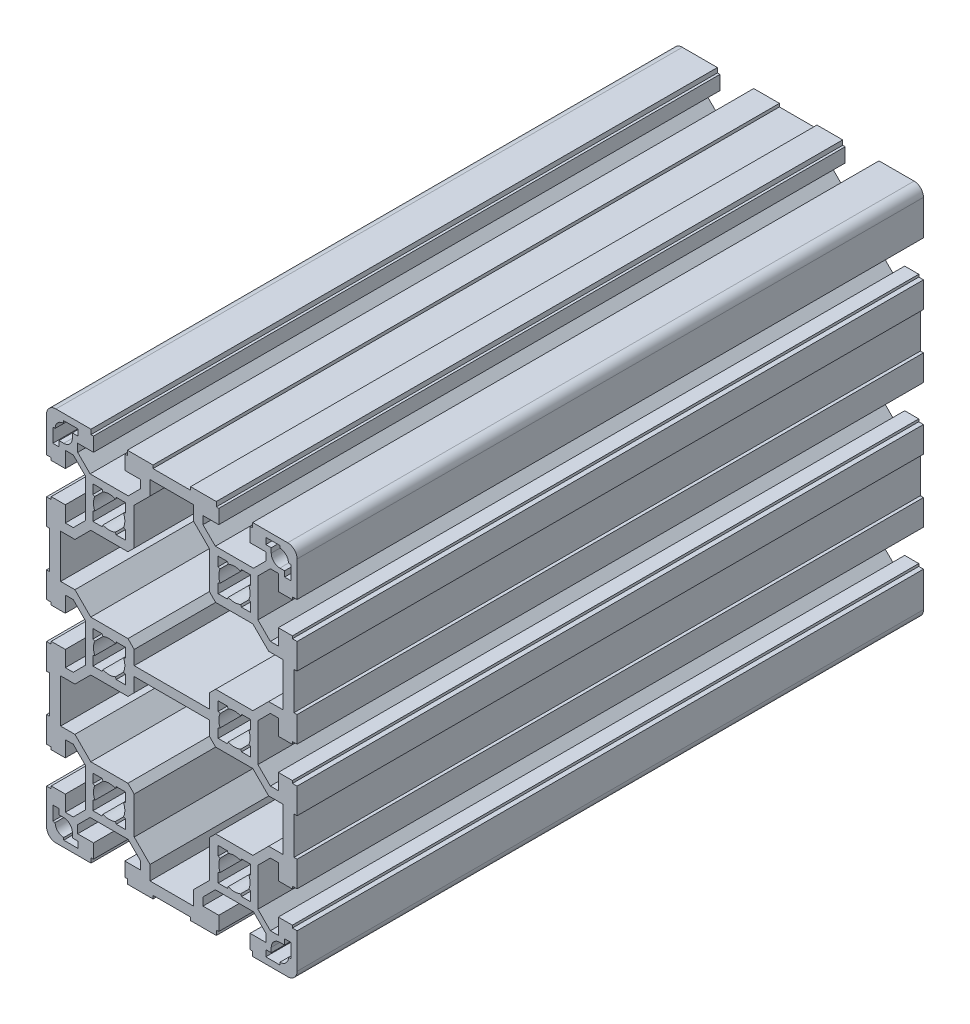
from build123d import *

# Parameters (mm, degrees)
BASE_EXTRUDE_DEPTH = 200


with BuildPart() as part:
    # Sketch1 → Base-Extrude (new body)
    with BuildSketch(Plane.XY):
        with BuildLine():
            Line((27.5, 46.085786046), (31.464214, 50.050000046))
            Line((31.464214, 50.050000046), (34, 50.050000046))
            Line((34, 50.050000046), (34, 45.000000046))
            Line((34, 45.000000046), (38.5, 45.000000046))
            Line((38.5, 45.000000046), (38.5, 45.800000046))
            Line((38.5, 45.800000046), (40, 45.800000046))
            Line((40, 45.800000046), (40, 57.000000046))
            ThreePointArc((40, 57.000000046), (39.121320344, 59.12132039), (37, 60.000000046))
            Line((37, 60.000000046), (25.8, 60.000000046))
            Line((25.8, 60.000000046), (25.8, 58.499999954))
            Line((25.8, 58.499999954), (25, 58.499999954))
            Line((25, 58.499999954), (25, 53.999999954))
            Line((25, 53.999999954), (30.05, 53.999999954))
            Line((30.05, 53.999999954), (30.05, 51.464213954))
            Line((30.05, 51.464213954), (26.085786, 47.499999954))
            Line((26.085786, 47.499999954), (13.914214, 47.499999954))
            Line((13.914214, 47.499999954), (9.95, 51.464213954))
            Line((9.95, 51.464213954), (9.95, 53.999999954))
            Line((9.95, 53.999999954), (15, 53.999999954))
            Line((15, 53.999999954), (15, 58.499999954))
            Line((15, 58.499999954), (14.2, 58.499999954))
            Line((14.2, 58.499999954), (14.2, 59.999999954))
            Line((14.2, 59.999999954), (6, 59.999999954))
            Line((6, 59.999999954), (6, 58.999999954))
            Line((6, 58.999999954), (-6, 58.999999954))
            Line((-6, 58.999999954), (-6, 59.999999954))
            Line((-6, 59.999999954), (-14.2, 59.999999954))
            Line((-14.2, 59.999999954), (-14.2, 58.499999954))
            Line((-14.2, 58.499999954), (-15, 58.499999954))
            Line((-15, 58.499999954), (-15, 53.999999954))
            Line((-15, 53.999999954), (-9.95, 53.999999954))
            Line((-9.95, 53.999999954), (-9.95, 51.464213954))
            Line((-9.95, 51.464213954), (-13.914214, 47.499999954))
            Line((-13.914214, 47.499999954), (-26.085786, 47.499999954))
            Line((-26.085786, 47.499999954), (-30.05, 51.464213954))
            Line((-30.05, 51.464213954), (-30.05, 53.999999954))
            Line((-30.05, 53.999999954), (-25, 53.999999954))
            Line((-25, 53.999999954), (-25, 58.499999954))
            Line((-25, 58.499999954), (-25.8, 58.499999954))
            Line((-25.8, 58.499999954), (-25.8, 60.000000046))
            Line((-25.8, 60.000000046), (-37, 60.000000046))
            ThreePointArc((-37, 60.000000046), (-39.121320344, 59.12132039), (-40, 57.000000046))
            Line((-40, 57.000000046), (-40, 45.800000046))
            Line((-40, 45.800000046), (-38.5, 45.800000046))
            Line((-38.5, 45.800000046), (-38.5, 45.000000046))
            Line((-38.5, 45.000000046), (-34, 45.000000046))
            Line((-34, 45.000000046), (-34, 50.050000046))
            Line((-34, 50.050000046), (-31.464214, 50.050000046))
            Line((-31.464214, 50.050000046), (-27.5, 46.085786046))
            Line((-27.5, 46.085786046), (-27.5, 33.914214047))
            Line((-27.5, 33.914214047), (-31.464214, 29.950000047))
            Line((-31.464214, 29.950000047), (-34, 29.950000047))
            Line((-34, 29.950000047), (-34, 35.000000047))
            Line((-34, 35.000000047), (-38.5, 35.000000047))
            Line((-38.5, 35.000000047), (-38.5, 34.200000047))
            Line((-38.5, 34.200000047), (-40, 34.200000047))
            Line((-40, 34.200000047), (-40, 26.000000047))
            Line((-40, 26.000000047), (-39, 26.000000047))
            Line((-39, 26.000000047), (-39, 14.000000047))
            Line((-39, 14.000000047), (-40, 14.000000047))
            Line((-40, 14.000000047), (-40, 5.800000047))
            Line((-40, 5.800000047), (-38.5, 5.800000047))
            Line((-38.5, 5.800000047), (-38.5, 5.000000047))
            Line((-38.5, 5.000000047), (-34, 5.000000047))
            Line((-34, 5.000000047), (-34, 10.050000047))
            Line((-34, 10.050000047), (-31.464214, 10.050000047))
            Line((-31.464214, 10.050000047), (-27.5, 6.085786047))
            Line((-27.5, 6.085786047), (-27.5, -6.085786045))
            Line((-27.5, -6.085786045), (-31.464214, -10.050000045))
            Line((-31.464214, -10.050000045), (-34, -10.050000045))
            Line((-34, -10.050000045), (-34, -5.000000045))
            Line((-34, -5.000000045), (-38.5, -5.000000045))
            Line((-38.5, -5.000000045), (-38.5, -5.800000045))
            Line((-38.5, -5.800000045), (-40, -5.800000045))
            Line((-40, -5.800000045), (-40, -14.000000045))
            Line((-40, -14.000000045), (-39, -14.000000045))
            Line((-39, -14.000000045), (-39, -26.000000045))
            Line((-39, -26.000000045), (-40, -26.000000045))
            Line((-40, -26.000000045), (-40, -34.200000045))
            Line((-40, -34.200000045), (-38.5, -34.200000045))
            Line((-38.5, -34.200000045), (-38.5, -35.000000045))
            Line((-38.5, -35.000000045), (-34, -35.000000045))
            Line((-34, -35.000000045), (-34, -29.950000045))
            Line((-34, -29.950000045), (-31.464214, -29.950000045))
            Line((-31.464214, -29.950000045), (-27.5, -33.914214045))
            Line((-27.5, -33.914214045), (-27.5, -46.085786044))
            Line((-27.5, -46.085786044), (-31.464214, -50.050000044))
            Line((-31.464214, -50.050000044), (-34, -50.050000044))
            Line((-34, -50.050000044), (-34, -45.000000044))
            Line((-34, -45.000000044), (-38.5, -45.000000044))
            Line((-38.5, -45.000000044), (-38.5, -45.800000044))
            Line((-38.5, -45.800000044), (-40, -45.800000044))
            Line((-40, -45.800000044), (-40, -57.000000044))
            ThreePointArc((-40, -57.000000044), (-39.121320344, -59.121320388), (-37, -60.000000044))
            Line((-37, -60.000000044), (-25.8, -60.000000044))
            Line((-25.8, -60.000000044), (-25.8, -58.499999952))
            Line((-25.8, -58.499999952), (-25, -58.499999952))
            Line((-25, -58.499999952), (-25, -53.999999952))
            Line((-25, -53.999999952), (-30.05, -53.999999952))
            Line((-30.05, -53.999999952), (-30.05, -51.464213952))
            Line((-30.05, -51.464213952), (-26.085786, -47.499999952))
            Line((-26.085786, -47.499999952), (-13.914214, -47.499999952))
            Line((-13.914214, -47.499999952), (-9.95, -51.464213952))
            Line((-9.95, -51.464213952), (-9.95, -53.999999952))
            Line((-9.95, -53.999999952), (-15, -53.999999952))
            Line((-15, -53.999999952), (-15, -58.499999952))
            Line((-15, -58.499999952), (-14.2, -58.499999952))
            Line((-14.2, -58.499999952), (-14.2, -59.999999952))
            Line((-14.2, -59.999999952), (-6, -59.999999952))
            Line((-6, -59.999999952), (-6, -58.999999952))
            Line((-6, -58.999999952), (6, -58.999999952))
            Line((6, -58.999999952), (6, -59.999999952))
            Line((6, -59.999999952), (14.2, -59.999999952))
            Line((14.2, -59.999999952), (14.2, -58.499999952))
            Line((14.2, -58.499999952), (15, -58.499999952))
            Line((15, -58.499999952), (15, -53.999999952))
            Line((15, -53.999999952), (9.95, -53.999999952))
            Line((9.95, -53.999999952), (9.95, -51.464213952))
            Line((9.95, -51.464213952), (13.914214, -47.499999952))
            Line((13.914214, -47.499999952), (26.085786, -47.499999952))
            Line((26.085786, -47.499999952), (30.05, -51.464213952))
            Line((30.05, -51.464213952), (30.05, -53.999999952))
            Line((30.05, -53.999999952), (25, -53.999999952))
            Line((25, -53.999999952), (25, -58.499999952))
            Line((25, -58.499999952), (25.8, -58.499999952))
            Line((25.8, -58.499999952), (25.8, -60.000000044))
            Line((25.8, -60.000000044), (37, -60.000000044))
            ThreePointArc((37, -60.000000044), (39.121320344, -59.121320388), (40, -57.000000044))
            Line((40, -57.000000044), (40, -45.800000044))
            Line((40, -45.800000044), (38.5, -45.800000044))
            Line((38.5, -45.800000044), (38.5, -45.000000044))
            Line((38.5, -45.000000044), (34, -45.000000044))
            Line((34, -45.000000044), (34, -50.050000044))
            Line((34, -50.050000044), (31.464214, -50.050000044))
            Line((31.464214, -50.050000044), (27.5, -46.085786044))
            Line((27.5, -46.085786044), (27.5, -33.914214045))
            Line((27.5, -33.914214045), (31.464214, -29.950000045))
            Line((31.464214, -29.950000045), (34, -29.950000045))
            Line((34, -29.950000045), (34, -35.000000045))
            Line((34, -35.000000045), (38.5, -35.000000045))
            Line((38.5, -35.000000045), (38.5, -34.200000045))
            Line((38.5, -34.200000045), (40, -34.200000045))
            Line((40, -34.200000045), (40, -26.000000045))
            Line((40, -26.000000045), (39, -26.000000045))
            Line((39, -26.000000045), (39, -14.000000045))
            Line((39, -14.000000045), (40, -14.000000045))
            Line((40, -14.000000045), (40, -5.800000045))
            Line((40, -5.800000045), (38.5, -5.800000045))
            Line((38.5, -5.800000045), (38.5, -5.000000045))
            Line((38.5, -5.000000045), (34, -5.000000045))
            Line((34, -5.000000045), (34, -10.050000045))
            Line((34, -10.050000045), (31.464214, -10.050000045))
            Line((31.464214, -10.050000045), (27.5, -6.085786045))
            Line((27.5, -6.085786045), (27.5, 6.085786047))
            Line((27.5, 6.085786047), (31.464214, 10.050000047))
            Line((31.464214, 10.050000047), (34, 10.050000047))
            Line((34, 10.050000047), (34, 5.000000047))
            Line((34, 5.000000047), (38.5, 5.000000047))
            Line((38.5, 5.000000047), (38.5, 5.800000047))
            Line((38.5, 5.800000047), (40, 5.800000047))
            Line((40, 5.800000047), (40, 14.000000047))
            Line((40, 14.000000047), (39, 14.000000047))
            Line((39, 14.000000047), (39, 26.000000047))
            Line((39, 26.000000047), (40, 26.000000047))
            Line((40, 26.000000047), (40, 34.200000047))
            Line((40, 34.200000047), (38.5, 34.200000047))
            Line((38.5, 34.200000047), (38.5, 35.000000047))
            Line((38.5, 35.000000047), (34, 35.000000047))
            Line((34, 35.000000047), (34, 29.950000047))
            Line((34, 29.950000047), (31.464214, 29.950000047))
            Line((31.464214, 29.950000047), (27.5, 33.914214047))
            Line((27.5, 33.914214047), (27.5, 46.085786046))
        make_face()
        Polygon((12, 45.878679956), (6.95, 50.928679956), (6.95, 55.499999956), (-6.95, 55.499999956), (-6.95, 50.928679956), (-12, 45.878679956), (-12, 33.999999956), (-14, 31.999999956), (-25.87868, 31.999999956), (-30.92868, 26.949999956), (-35.5, 26.949999956), (-35.5, 13.049999954), (-30.92868, 13.049999954), (-25.87868, 7.999999954), (-14, 7.999999954), (-12, 5.999999954), (-12, 1.499999954), (12, 1.499999954), (12, 5.999999954), (14, 7.999999954), (25.87868, 7.999999954), (30.92868, 13.049999954), (35.5, 13.049999954), (35.5, 26.949999956), (30.92868, 26.949999956), (25.87868, 31.999999956), (14, 31.999999956), (12, 33.999999956), align=None, mode=Mode.SUBTRACT)
        with BuildLine():
            Line((-14.799999974, 2.260288021), (-15.414462038, 1.993198916))
            ThreePointArc((-15.414462038, 1.993198916), (-14.99999997, 1e-09), (-15.414462038, -1.993198914))
            Line((-15.414462038, -1.993198914), (-14.799999974, -2.260288019))
            Line((-14.799999974, -2.260288019), (-14.799999974, -5.199999953))
            Line((-14.799999974, -5.199999953), (-17.73971204, -5.199999953))
            Line((-17.73971204, -5.199999953), (-18.00680104, -4.585537953))
            ThreePointArc((-18.00680104, -4.585537953), (-19.999999985, -5.000000049), (-21.993198935, -4.585537981))
            Line((-21.993198935, -4.585537981), (-22.26028804, -5.200000045))
            Line((-22.26028804, -5.200000045), (-25.199999974, -5.200000045))
            Line((-25.199999974, -5.200000045), (-25.199999974, -2.260287979))
            Line((-25.199999974, -2.260287979), (-24.585537974, -1.993198979))
            ThreePointArc((-24.585537974, -1.993198979), (-25.00000007, 1e-09), (-24.585537974, 1.993198981))
            Line((-24.585537974, 1.993198981), (-25.199999974, 2.260287981))
            Line((-25.199999974, 2.260287981), (-25.199999974, 5.200000047))
            Line((-25.199999974, 5.200000047), (-22.26028804, 5.200000047))
            Line((-22.26028804, 5.200000047), (-21.993198935, 4.585537983))
            ThreePointArc((-21.993198935, 4.585537983), (-19.999999985, 5.000000051), (-18.00680104, 4.585537955))
            Line((-18.00680104, 4.585537955), (-17.73971204, 5.199999955))
            Line((-17.73971204, 5.199999955), (-14.799999974, 5.199999955))
            Line((-14.799999974, 5.199999955), (-14.799999974, 2.260288021))
        make_face(mode=Mode.SUBTRACT)
        with BuildLine():
            Line((34.5, 51.749999954), (36, 51.749999954))
            Line((36, 51.749999954), (36, 49.999999954))
            Line((36, 49.999999954), (38, 49.999999954))
            Line((38, 49.999999954), (38, 54.499999954))
            Line((38, 54.499999954), (37.25, 54.499999954))
            ThreePointArc((37.25, 54.499999954), (36.444543648, 56.444543602), (34.5, 57.249999954))
            Line((34.5, 57.249999954), (34.5, 57.999999954))
            Line((34.5, 57.999999954), (30, 57.999999954))
            Line((30, 57.999999954), (30, 55.999999954))
            Line((30, 55.999999954), (31.75, 55.999999954))
            Line((31.75, 55.999999954), (31.75, 54.499999954))
            ThreePointArc((31.75, 54.499999954), (32.555456352, 52.555456306), (34.5, 51.749999954))
        make_face(mode=Mode.SUBTRACT)
        with BuildLine():
            Line((17.739712, 34.799999956), (18.006801105, 35.41446202))
            ThreePointArc((18.006801105, 35.41446202), (20.000000055, 34.999999952), (21.993199, 35.414462048))
            Line((21.993199, 35.414462048), (22.260288, 34.800000048))
            Line((22.260288, 34.800000048), (25.2, 34.800000048))
            Line((25.2, 34.800000048), (25.2, 37.739712048))
            Line((25.2, 37.739712048), (24.585538016, 38.006801118))
            ThreePointArc((24.585538016, 38.006801118), (25.00000007, 40.000000054), (24.585537974, 41.993198982))
            Line((24.585537974, 41.993198982), (25.199999974, 42.260287982))
            Line((25.199999974, 42.260287982), (25.199999974, 45.200000048))
            Line((25.199999974, 45.200000048), (22.26028804, 45.200000048))
            Line((22.26028804, 45.200000048), (21.993198935, 44.585537984))
            ThreePointArc((21.993198935, 44.585537984), (19.999999985, 45.000000052), (18.00680104, 44.585537956))
            Line((18.00680104, 44.585537956), (17.73971204, 45.199999956))
            Line((17.73971204, 45.199999956), (14.799999974, 45.199999956))
            Line((14.799999974, 45.199999956), (14.799999974, 42.260288022))
            Line((14.799999974, 42.260288022), (15.414462038, 41.993198917))
            ThreePointArc((15.414462038, 41.993198917), (14.99999997, 39.99999995), (15.41446208, 38.006800991))
            Line((15.41446208, 38.006800991), (14.8, 37.739711956))
            Line((14.8, 37.739711956), (14.8, 34.799999956))
            Line((14.8, 34.799999956), (17.739712, 34.799999956))
        make_face(mode=Mode.SUBTRACT)
        with BuildLine():
            Line((-14.8, 34.799999956), (-17.739712, 34.799999956))
            Line((-17.739712, 34.799999956), (-18.006801105, 35.41446202))
            ThreePointArc((-18.006801105, 35.41446202), (-20.000000055, 34.999999952), (-21.993199, 35.414462048))
            Line((-21.993199, 35.414462048), (-22.260288, 34.800000048))
            Line((-22.260288, 34.800000048), (-25.2, 34.800000048))
            Line((-25.2, 34.800000048), (-25.2, 37.739712048))
            Line((-25.2, 37.739712048), (-24.585538016, 38.006801118))
            ThreePointArc((-24.585538016, 38.006801118), (-25.00000007, 40.000000054), (-24.585537974, 41.993198982))
            Line((-24.585537974, 41.993198982), (-25.199999974, 42.260287982))
            Line((-25.199999974, 42.260287982), (-25.199999974, 45.200000048))
            Line((-25.199999974, 45.200000048), (-22.26028804, 45.200000048))
            Line((-22.26028804, 45.200000048), (-21.993198935, 44.585537984))
            ThreePointArc((-21.993198935, 44.585537984), (-19.999999985, 45.000000052), (-18.00680104, 44.585537956))
            Line((-18.00680104, 44.585537956), (-17.73971204, 45.199999956))
            Line((-17.73971204, 45.199999956), (-14.799999974, 45.199999956))
            Line((-14.799999974, 45.199999956), (-14.799999974, 42.260288022))
            Line((-14.799999974, 42.260288022), (-15.414462038, 41.993198917))
            ThreePointArc((-15.414462038, 41.993198917), (-14.99999997, 39.99999995), (-15.41446208, 38.006800991))
            Line((-15.41446208, 38.006800991), (-14.8, 37.739711956))
            Line((-14.8, 37.739711956), (-14.8, 34.799999956))
        make_face(mode=Mode.SUBTRACT)
        with BuildLine():
            Line((24.585537974, 1.993198981), (25.199999974, 2.260287981))
            Line((25.199999974, 2.260287981), (25.199999974, 5.200000047))
            Line((25.199999974, 5.200000047), (22.26028804, 5.200000047))
            Line((22.26028804, 5.200000047), (21.993198935, 4.585537983))
            ThreePointArc((21.993198935, 4.585537983), (19.999999985, 5.000000051), (18.00680104, 4.585537955))
            Line((18.00680104, 4.585537955), (17.73971204, 5.199999955))
            Line((17.73971204, 5.199999955), (14.799999974, 5.199999955))
            Line((14.799999974, 5.199999955), (14.799999974, 2.260288021))
            Line((14.799999974, 2.260288021), (15.414462038, 1.993198916))
            ThreePointArc((15.414462038, 1.993198916), (14.99999997, 1e-09), (15.414462038, -1.993198914))
            Line((15.414462038, -1.993198914), (14.799999974, -2.260288019))
            Line((14.799999974, -2.260288019), (14.799999974, -5.199999953))
            Line((14.799999974, -5.199999953), (17.73971204, -5.199999953))
            Line((17.73971204, -5.199999953), (18.00680104, -4.585537953))
            ThreePointArc((18.00680104, -4.585537953), (19.999999985, -5.000000049), (21.993198935, -4.585537981))
            Line((21.993198935, -4.585537981), (22.26028804, -5.200000045))
            Line((22.26028804, -5.200000045), (25.199999974, -5.200000045))
            Line((25.199999974, -5.200000045), (25.199999974, -2.260287979))
            Line((25.199999974, -2.260287979), (24.585537974, -1.993198979))
            ThreePointArc((24.585537974, -1.993198979), (25.00000007, 1e-09), (24.585537974, 1.993198981))
        make_face(mode=Mode.SUBTRACT)
        with BuildLine():
            Line((-31.75, 55.999999954), (-31.75, 54.499999954))
            ThreePointArc((-31.75, 54.499999954), (-32.555456352, 52.555456306), (-34.5, 51.749999954))
            Line((-34.5, 51.749999954), (-36, 51.749999954))
            Line((-36, 51.749999954), (-36, 49.999999954))
            Line((-36, 49.999999954), (-38, 49.999999954))
            Line((-38, 49.999999954), (-38, 54.499999954))
            Line((-38, 54.499999954), (-37.25, 54.499999954))
            ThreePointArc((-37.25, 54.499999954), (-36.444543648, 56.444543602), (-34.5, 57.249999954))
            Line((-34.5, 57.249999954), (-34.5, 57.999999954))
            Line((-34.5, 57.999999954), (-30, 57.999999954))
            Line((-30, 57.999999954), (-30, 55.999999954))
            Line((-30, 55.999999954), (-31.75, 55.999999954))
        make_face(mode=Mode.SUBTRACT)
        Polygon((-12, -45.878679954), (-6.95, -50.928679954), (-6.95, -55.499999954), (6.95, -55.499999954), (6.95, -50.928679954), (12, -45.878679954), (12, -33.999999954), (14, -31.999999954), (25.87868, -31.999999954), (30.92868, -26.949999954), (35.5, -26.949999954), (35.5, -13.049999952), (30.92868, -13.049999952), (25.87868, -7.999999952), (14, -7.999999952), (12, -5.999999952), (12, -1.499999952), (-12, -1.499999952), (-12, -5.999999952), (-14, -7.999999952), (-25.87868, -7.999999952), (-30.92868, -13.049999952), (-35.5, -13.049999952), (-35.5, -26.949999954), (-30.92868, -26.949999954), (-25.87868, -31.999999954), (-14, -31.999999954), (-12, -33.999999954), align=None, mode=Mode.SUBTRACT)
        with BuildLine():
            Line((-34.5, -51.749999952), (-36, -51.749999952))
            Line((-36, -51.749999952), (-36, -49.999999952))
            Line((-36, -49.999999952), (-38, -49.999999952))
            Line((-38, -49.999999952), (-38, -54.499999952))
            Line((-38, -54.499999952), (-37.25, -54.499999952))
            ThreePointArc((-37.25, -54.499999952), (-36.444543648, -56.4445436), (-34.5, -57.249999952))
            Line((-34.5, -57.249999952), (-34.5, -57.999999952))
            Line((-34.5, -57.999999952), (-30, -57.999999952))
            Line((-30, -57.999999952), (-30, -55.999999952))
            Line((-30, -55.999999952), (-31.75, -55.999999952))
            Line((-31.75, -55.999999952), (-31.75, -54.499999952))
            ThreePointArc((-31.75, -54.499999952), (-32.555456352, -52.555456304), (-34.5, -51.749999952))
        make_face(mode=Mode.SUBTRACT)
        with BuildLine():
            Line((14.8, -34.799999954), (17.739712, -34.799999954))
            Line((17.739712, -34.799999954), (18.006801105, -35.414462018))
            ThreePointArc((18.006801105, -35.414462018), (20.000000055, -34.99999995), (21.993199, -35.414462046))
            Line((21.993199, -35.414462046), (22.260288, -34.800000046))
            Line((22.260288, -34.800000046), (25.2, -34.800000046))
            Line((25.2, -34.800000046), (25.2, -37.739712046))
            Line((25.2, -37.739712046), (24.585538016, -38.006801116))
            ThreePointArc((24.585538016, -38.006801116), (25.00000007, -40.000000052), (24.585537974, -41.99319898))
            Line((24.585537974, -41.99319898), (25.199999974, -42.26028798))
            Line((25.199999974, -42.26028798), (25.199999974, -45.200000046))
            Line((25.199999974, -45.200000046), (22.26028804, -45.200000046))
            Line((22.26028804, -45.200000046), (21.993198935, -44.585537982))
            ThreePointArc((21.993198935, -44.585537982), (19.999999985, -45.00000005), (18.00680104, -44.585537954))
            Line((18.00680104, -44.585537954), (17.73971204, -45.199999954))
            Line((17.73971204, -45.199999954), (14.799999974, -45.199999954))
            Line((14.799999974, -45.199999954), (14.799999974, -42.26028802))
            Line((14.799999974, -42.26028802), (15.414462038, -41.993198915))
            ThreePointArc((15.414462038, -41.993198915), (14.99999997, -39.999999948), (15.41446208, -38.006800989))
            Line((15.41446208, -38.006800989), (14.8, -37.739711954))
            Line((14.8, -37.739711954), (14.8, -34.799999954))
        make_face(mode=Mode.SUBTRACT)
        with BuildLine():
            Line((-17.739712, -34.799999954), (-18.006801105, -35.414462018))
            ThreePointArc((-18.006801105, -35.414462018), (-20.000000055, -34.99999995), (-21.993199, -35.414462046))
            Line((-21.993199, -35.414462046), (-22.260288, -34.800000046))
            Line((-22.260288, -34.800000046), (-25.2, -34.800000046))
            Line((-25.2, -34.800000046), (-25.2, -37.739712046))
            Line((-25.2, -37.739712046), (-24.585538016, -38.006801116))
            ThreePointArc((-24.585538016, -38.006801116), (-25.00000007, -40.000000052), (-24.585537974, -41.99319898))
            Line((-24.585537974, -41.99319898), (-25.199999974, -42.26028798))
            Line((-25.199999974, -42.26028798), (-25.199999974, -45.200000046))
            Line((-25.199999974, -45.200000046), (-22.26028804, -45.200000046))
            Line((-22.26028804, -45.200000046), (-21.993198935, -44.585537982))
            ThreePointArc((-21.993198935, -44.585537982), (-19.999999985, -45.00000005), (-18.00680104, -44.585537954))
            Line((-18.00680104, -44.585537954), (-17.73971204, -45.199999954))
            Line((-17.73971204, -45.199999954), (-14.799999974, -45.199999954))
            Line((-14.799999974, -45.199999954), (-14.799999974, -42.26028802))
            Line((-14.799999974, -42.26028802), (-15.414462038, -41.993198915))
            ThreePointArc((-15.414462038, -41.993198915), (-14.99999997, -39.999999948), (-15.41446208, -38.006800989))
            Line((-15.41446208, -38.006800989), (-14.8, -37.739711954))
            Line((-14.8, -37.739711954), (-14.8, -34.799999954))
            Line((-14.8, -34.799999954), (-17.739712, -34.799999954))
        make_face(mode=Mode.SUBTRACT)
        with BuildLine():
            Line((31.75, -55.999999952), (31.75, -54.499999952))
            ThreePointArc((31.75, -54.499999952), (32.555456352, -52.555456304), (34.5, -51.749999952))
            Line((34.5, -51.749999952), (36, -51.749999952))
            Line((36, -51.749999952), (36, -49.999999952))
            Line((36, -49.999999952), (38, -49.999999952))
            Line((38, -49.999999952), (38, -54.499999952))
            Line((38, -54.499999952), (37.25, -54.499999952))
            ThreePointArc((37.25, -54.499999952), (36.444543648, -56.4445436), (34.5, -57.249999952))
            Line((34.5, -57.249999952), (34.5, -57.999999952))
            Line((34.5, -57.999999952), (30, -57.999999952))
            Line((30, -57.999999952), (30, -55.999999952))
            Line((30, -55.999999952), (31.75, -55.999999952))
        make_face(mode=Mode.SUBTRACT)
    extrude(amount=-BASE_EXTRUDE_DEPTH)


solid = part.part
